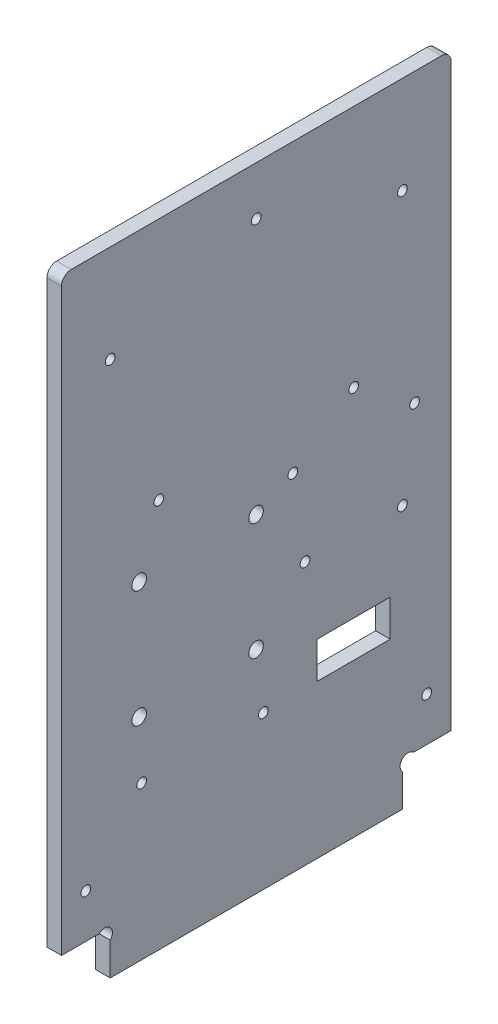
from build123d import *

# Parameters (mm, degrees)
EXTRUSION1_DEPTH        = 3
ESQUISSE2_R             = 1
ESQUISSE2_R_2           = 1.5
ENL_V_MAT_EXTRU_1_DEPTH = 4
ESQUISSE3_W             = 15
ESQUISSE3_H             = 7.5
ENL_V_MAT_EXTRU_2_DEPTH = 4
ESQUISSE4_R             = 1
ENL_V_MAT_EXTRU_3_DEPTH = 4
CONG_1_R                = 2
ESQUISSE5_R             = 1
ENL_V_MAT_EXTRU_6_DEPTH = 4


with BuildPart() as part:
    # Esquisse1 → Extrusion1 (new body)
    with BuildSketch(Plane(origin=(0, 0, 0), x_dir=(0, 0, -1), z_dir=(1, 0, 0))):
        with BuildLine():
            Line((10, 6.7372583), (10, 0))
            Line((10, 0), (70, 0))
            Line((70, 0), (70, 6.7372583))
            ThreePointArc((70, 6.7372583), (70, 9), (72.2627417, 9))
            Line((72.2627417, 9), (80, 9))
            Line((80, 9), (80, 130))
            Line((80, 130), (0, 130))
            Line((0, 130), (0, 9))
            Line((0, 9), (7.7372583, 9))
            ThreePointArc((7.7372583, 9), (10, 9), (10, 6.7372583))
        make_face()
    extrude(amount=EXTRUSION1_DEPTH)

    # Esquisse2 → Enlèv. mat.-Extru.1 (cut, through all)
    with BuildSketch(Plane(origin=(3, 0, 0), x_dir=(0, 0, -1), z_dir=(1, 0, 0))):
        with Locations((60, 80)):
            Circle(ESQUISSE2_R)
        with Locations((10, 110)):
            Circle(ESQUISSE2_R)
        with Locations(Location((20, 80, 0), (0, 0, 180))):  # turned: the seam where the file's is
            Circle(ESQUISSE2_R)
        with Locations((70, 110)):
            Circle(ESQUISSE2_R)
        with Locations((15.95, 67.45)):
            Circle(ESQUISSE2_R_2)
        with Locations((15.95, 43.45)):
            Circle(ESQUISSE2_R_2)
        with Locations((39.95, 43.45)):
            Circle(ESQUISSE2_R_2)
        with Locations((39.95, 67.45)):
            Circle(ESQUISSE2_R_2)
        with Locations((40, 120)):
            Circle(ESQUISSE2_R)
        with Locations((70, 54)):
            Circle(ESQUISSE2_R)
        with Locations((50, 54)):
            Circle(ESQUISSE2_R)
    extrude(amount=-ENL_V_MAT_EXTRU_1_DEPTH, mode=Mode.SUBTRACT)

    # Esquisse3 → Enlèv. mat.-Extru.2 (cut, through all)
    with BuildSketch(Plane.ZY):
        with Locations((-60, 35.25)):
            Rectangle(ESQUISSE3_W, ESQUISSE3_H)
    extrude(amount=-ENL_V_MAT_EXTRU_2_DEPTH, mode=Mode.SUBTRACT)

    # Esquisse4 → Enlèv. mat.-Extru.3 (cut, through all)
    with BuildSketch(Plane(origin=(3, 0, 0), x_dir=(0, 0, -1), z_dir=(1, 0, 0))):
        with Locations((75, 18)):
            Circle(ESQUISSE4_R)
        with Locations((5, 18)):
            Circle(ESQUISSE4_R)
    extrude(amount=-ENL_V_MAT_EXTRU_3_DEPTH, mode=Mode.SUBTRACT)

    # Congé1
    cong_1_edges = [part.edges().sort_by_distance(p)[0] for p in [
        (1.5, 130, 0),
        (1.5, 130, -80),
    ]]
    fillet(cong_1_edges, radius=CONG_1_R)

    # Esquisse5 → Enlèv. mat.-Extru.6 (cut, through all)
    with BuildSketch(Plane(origin=(3, 0, 0), x_dir=(0, 0, -1), z_dir=(1, 0, 0))):
        with Locations((16.45, 31.45)):
            Circle(ESQUISSE5_R)
        with Locations((41.45, 31.45)):
            Circle(ESQUISSE5_R)
        with Locations((47.5, 71)):
            Circle(ESQUISSE5_R)
        with Locations((72.5, 71)):
            Circle(ESQUISSE5_R)
    extrude(amount=-ENL_V_MAT_EXTRU_6_DEPTH, mode=Mode.SUBTRACT)


solid = part.part
